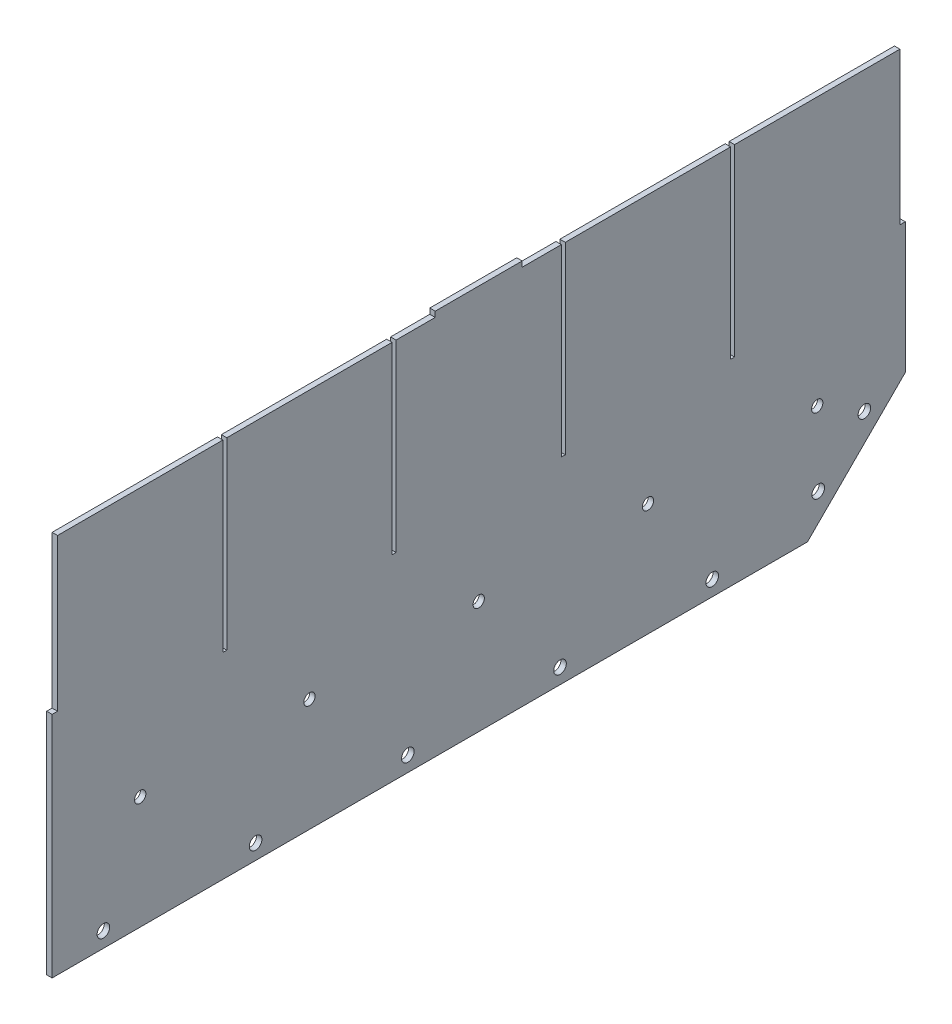
from build123d import *

# Parameters (mm, degrees)
SKETCH1_W            = 498.348
SKETCH1_H            = 165.1
BOSS_EXTRUDE1_DEPTH  = 1.5875
BOSS_EXTRUDE2_DEPTH  = 3.175
CUT_EXTRUDE1_DEPTH   = 3.175
LPATTERN1_COUNT      = 5
LPATTERN1_PITCH      = 88.9
SKETCH4_R            = 3.675
CUT_EXTRUDE2_DEPTH   = 4.175
LPATTERN2_COUNT      = 2
LPATTERN2_PITCH      = 38.1
SKETCH5_W            = 3.175
SKETCH5_H            = 88.9
CUT_EXTRUDE3_DEPTH   = 4.175
SKETCH6_W            = 2.286
SKETCH6_H            = 107.442
CUT_EXTRUDE4_DEPTH   = 4.175
LPATTERN3_COUNT      = 4
LPATTERN3_PITCH      = 98.8568
SKETCH7_W            = 50.8
SKETCH7_H            = 3.175
BOSS_EXTRUDE3_DEPTH  = 3.175
M6_CLEARANCE_HOLE1_D = 6.6
LPATTERN4_COUNT      = 3
LPATTERN4_PITCH      = 98.8568
LPATTERN4_COL_COUNT  = 3
LPATTERN4_COL_PITCH  = 98.8568


with BuildPart() as part:
    # Sketch1 → Boss-Extrude1 (new body, symmetric)
    with BuildSketch(Plane(origin=(0, 0, 0), x_dir=(0, 0, -1), z_dir=(1, 0, 0))):
        Rectangle(SKETCH1_W, SKETCH1_H)
    extrude(amount=BOSS_EXTRUDE1_DEPTH, both=True)

    # Sketch2 → Boss-Extrude2 (add)
    with BuildSketch(Plane(origin=(1.5875, 0, 0), x_dir=(0, 0, -1), z_dir=(1, 0, 0))):
        Polygon((-249.174, -139.7), (192.024, -139.7), (249.174, -82.55), (-249.174, -82.55), align=None)
    extrude(amount=-BOSS_EXTRUDE2_DEPTH)

    # Sketch3 → Cut-Extrude1 (cut)
    with BuildSketch(Plane(origin=(1.5875, 0, 0), x_dir=(0, 0, -1), z_dir=(1, 0, 0))):
        with BuildLine():
            ThreePointArc((-222.877, -130.81), (-221.800617421, -133.408617421), (-219.202, -134.485))
            Line((-219.202, -134.485), (-219.202, -130.81))
            Line((-219.202, -130.81), (-222.877, -130.81))
        make_face()
        with BuildLine():
            Line((-219.202, -130.81), (-219.202, -134.485))
            ThreePointArc((-219.202, -134.485), (-216.603382579, -133.408617421), (-215.527, -130.81))
            ThreePointArc((-215.527, -130.81), (-219.202, -127.135), (-222.877, -130.81))
            Line((-222.877, -130.81), (-219.202, -130.81))
        make_face()
    cut_extrude1 = extrude(amount=-CUT_EXTRUDE1_DEPTH, mode=Mode.SUBTRACT)

    # LPattern1: Cut-Extrude1 ×5
    with Locations(*[(0, 0, -i * LPATTERN1_PITCH) for i in range(1, LPATTERN1_COUNT)]):
        add(cut_extrude1, mode=Mode.SUBTRACT)

    # Sketch4 → Cut-Extrude2 (cut, through all)
    with BuildSketch(Plane(origin=(1.5875, 0, 0), x_dir=(0, 0, -1), z_dir=(1, 0, 0))):
        with Locations((198.310179285, -117.249359697)):
            Circle(SKETCH4_R)
    cut_extrude2 = extrude(amount=-CUT_EXTRUDE2_DEPTH, mode=Mode.SUBTRACT)

    # LPattern2: Cut-Extrude2 ×2
    with Locations(*[Vector(0, 0.707106781, -0.707106781) * (i * LPATTERN2_PITCH) for i in range(1, LPATTERN2_COUNT)]):
        add(cut_extrude2, mode=Mode.SUBTRACT)

    # Sketch5 → Cut-Extrude3 (cut, through all)
    with BuildSketch(Plane.ZY.offset(1.5875)):
        with Locations((-247.5865, 38.1)):
            Rectangle(SKETCH5_W, SKETCH5_H)
        with Locations((247.5865, 38.1)):
            Rectangle(SKETCH5_W, SKETCH5_H)
    extrude(amount=-CUT_EXTRUDE3_DEPTH, mode=Mode.SUBTRACT)

    # Sketch6 → Cut-Extrude4 (cut, through all)
    with BuildSketch(Plane.ZY.offset(1.5875)):
        with Locations((-148.2852, 28.829)):
            Rectangle(SKETCH6_W, SKETCH6_H)
    cut_extrude4 = extrude(amount=-CUT_EXTRUDE4_DEPTH, mode=Mode.SUBTRACT)

    # LPattern3: Cut-Extrude4 ×4
    with Locations(*[(0, 0, i * LPATTERN3_PITCH) for i in range(1, LPATTERN3_COUNT)]):
        add(cut_extrude4, mode=Mode.SUBTRACT)

    # Sketch7 → Boss-Extrude3 (add)
    with BuildSketch(Plane.ZY.offset(1.5875)):
        with Locations((0, 84.1375)):
            Rectangle(SKETCH7_W, SKETCH7_H)
    extrude(amount=-BOSS_EXTRUDE3_DEPTH)

    # M6 Clearance Hole1 (through all)
    with Locations(Plane(origin=(1.5875, 0, 0), x_dir=(0, 0, -1), z_dir=(1, 0, 0))):
        with Locations((0, -73.8124)):
            m6_clearance_hole1 = Hole(M6_CLEARANCE_HOLE1_D / 2)

    # LPattern4: M6 Clearance Hole1 ×3
    with Locations(*[(0, 0, i * LPATTERN4_PITCH) for i in range(1, LPATTERN4_COUNT)]):
        add(m6_clearance_hole1, mode=Mode.SUBTRACT)

    # LPattern4 col: M6 Clearance Hole1 ×3
    with Locations(*[(0, 0, -i * LPATTERN4_COL_PITCH) for i in range(1, LPATTERN4_COL_COUNT)]):
        add(m6_clearance_hole1, mode=Mode.SUBTRACT)


solid = part.part
